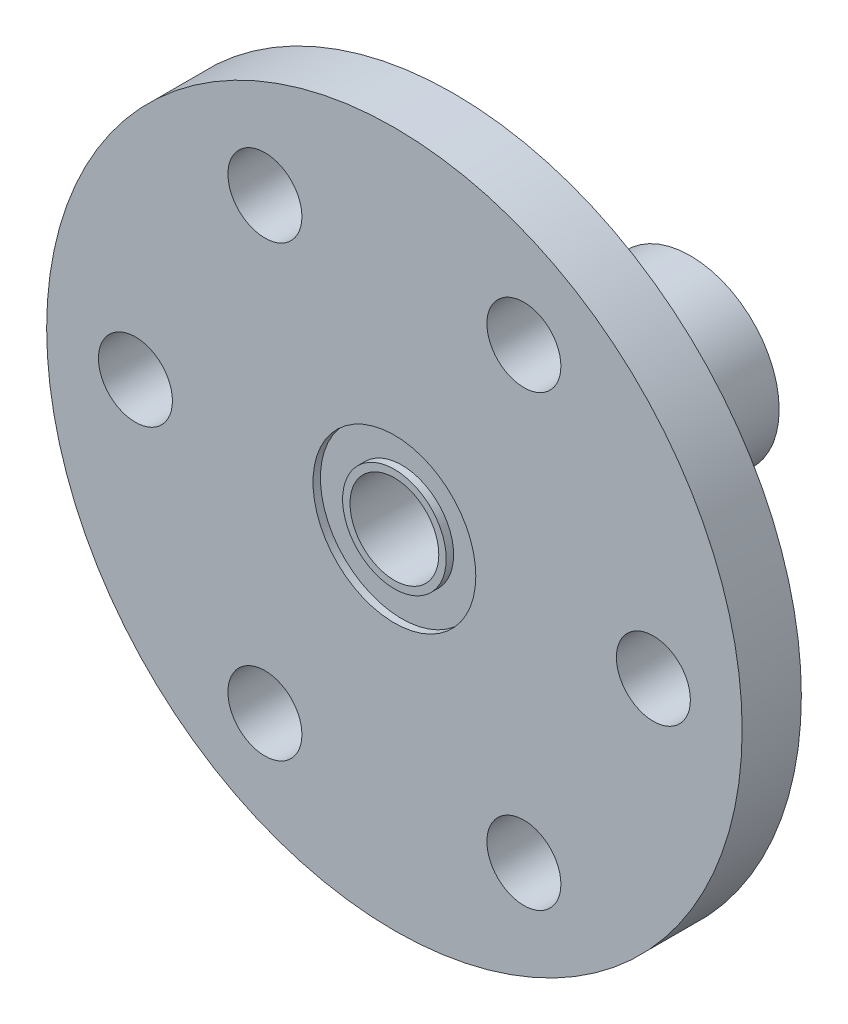
from build123d import *

# Parameters (mm, degrees)
SKETCH1_R               = 23.5
SKETCH1_R_2             = 3
BOSS_EXTRUDE1_DEPTH     = 4
SKETCH2_R               = 6
SKETCH2_R_2             = 3
BOSS_EXTRUDE2_DEPTH     = 16
SKETCH3_R               = 2.5
CUT_EXTRUDE1_DEPTH      = 21
SKETCH5_R               = 5.5
SKETCH5_R_2             = 3.5
CUT_EXTRUDE3_DEPTH      = 0.5
SKETCH6_R               = 5.5
SKETCH6_R_2             = 3.5
CUT_EXTRUDE4_DEPTH      = 0.5
SKETCH7_R               = 2
CUT_EXTRUDE5_DEPTH      = 10
CUT_EXTRUDE5_DEPTH_BACK = 10


with BuildPart() as part:
    # Sketch1 → Boss-Extrude1 (new body)
    with BuildSketch(Plane.XY):
        Circle(SKETCH1_R)
        Circle(SKETCH1_R_2, mode=Mode.SUBTRACT)
    extrude(amount=BOSS_EXTRUDE1_DEPTH)

    # Sketch2 → Boss-Extrude2 (add)
    with BuildSketch(Plane(origin=(0, 0, 0), x_dir=(-1, 0, 0), z_dir=(0, 0, -1))):
        Circle(SKETCH2_R)
        Circle(SKETCH2_R_2, mode=Mode.SUBTRACT)
    extrude(amount=BOSS_EXTRUDE2_DEPTH)

    # Sketch3 → Cut-Extrude1 (cut, through all)
    with BuildSketch(Plane.XY.offset(4)):
        with Locations((-17.5, 0)):
            Circle(SKETCH3_R)
        with Locations((-8.75, 15.155444566)):
            Circle(SKETCH3_R)
        with Locations((8.75, 15.155444566)):
            Circle(SKETCH3_R)
        with Locations((17.5, 0)):
            Circle(SKETCH3_R)
        with Locations((8.75, -15.155444566)):
            Circle(SKETCH3_R)
        with Locations((-8.75, -15.155444566)):
            Circle(SKETCH3_R)
    extrude(amount=-CUT_EXTRUDE1_DEPTH, mode=Mode.SUBTRACT)

    # Sketch5 → Cut-Extrude3 (cut)
    with BuildSketch(Plane.XY.offset(4)):
        Circle(SKETCH5_R)
        Circle(SKETCH5_R_2, mode=Mode.SUBTRACT)
    extrude(amount=-CUT_EXTRUDE3_DEPTH, mode=Mode.SUBTRACT)

    # Sketch6 → Cut-Extrude4 (cut)
    with BuildSketch(Plane(origin=(0, 0, -16), x_dir=(-1, 0, 0), z_dir=(0, 0, -1))):
        Circle(SKETCH6_R)
        Circle(SKETCH6_R_2, mode=Mode.SUBTRACT)
    extrude(amount=-CUT_EXTRUDE4_DEPTH, mode=Mode.SUBTRACT)

    # Sketch7 → Cut-Extrude5 (cut, two sides)
    with BuildSketch(Plane(origin=(0, 0, 0), x_dir=(1, 0, 0), z_dir=(0, 1, 0))) as cut_extrude5_sk:
        with Locations((0, 8)):
            Circle(SKETCH7_R)
    extrude(amount=CUT_EXTRUDE5_DEPTH, mode=Mode.SUBTRACT)
    extrude(cut_extrude5_sk.sketch, amount=-CUT_EXTRUDE5_DEPTH_BACK, mode=Mode.SUBTRACT)


solid = part.part
